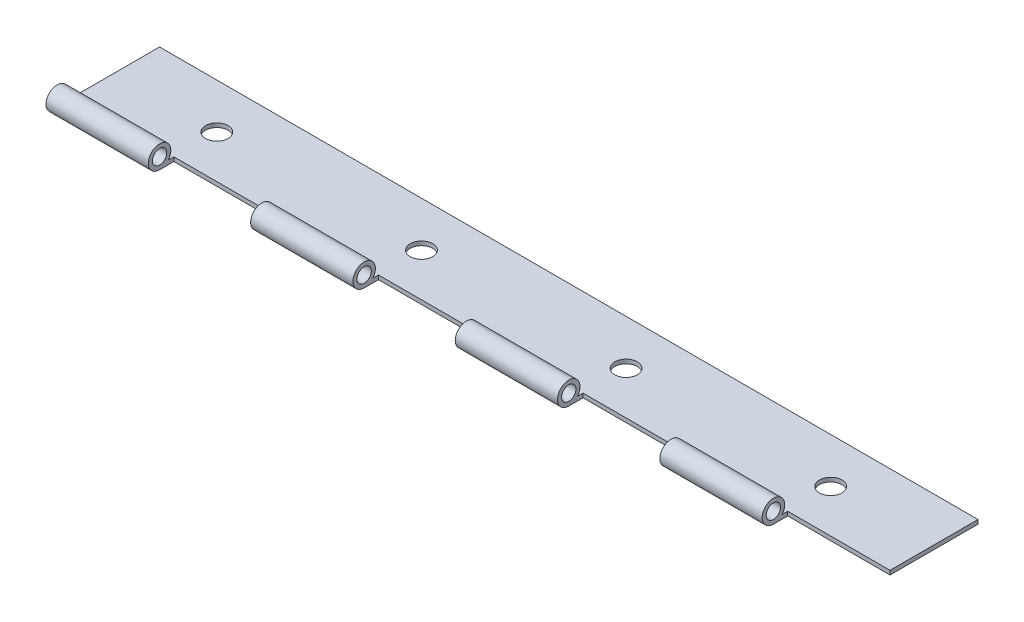
from build123d import *

# Parameters (mm, degrees)
SKETCH1_R           = 1.778
BOSS_EXTRUDE1_DEPTH = 101.6
SKETCH2_R           = 2.794
SKETCH2_W           = 25.4
SKETCH2_H           = 6.35
CUT_EXTRUDE1_DEPTH  = 914.4
LPATTERN1_COUNT     = 3
LPATTERN1_PITCH     = 50.8
LPATTERN2_COUNT     = 3
LPATTERN2_PITCH     = 50.8


with BuildPart() as part:
    # Sketch1 → Boss-Extrude1 (new body, symmetric)
    with BuildSketch(Plane(origin=(0, 0, 0), x_dir=(0, 0, -1), z_dir=(1, 0, 0))):
        with BuildLine():
            Line((0, -2.794), (25.4, -2.794))
            Line((25.4, -2.794), (25.4, -1.778))
            Line((25.4, -1.778), (2.155261469, -1.778))
            ThreePointArc((2.155261469, -1.778), (-1.191365603, 2.52726809), (0, -2.794))
        make_face()
        Circle(SKETCH1_R, mode=Mode.SUBTRACT)
    extrude(amount=BOSS_EXTRUDE1_DEPTH, both=True)

    # Sketch2 → Cut-Extrude1 (cut, symmetric)
    with BuildSketch(Plane(origin=(0, -1.778, 0), x_dir=(1, 0, 0), z_dir=(0, 1, 0))):
        with Locations((-25.4, 14.224)):
            Circle(SKETCH2_R)
        with Locations((-12.7, 0.381)):
            Rectangle(SKETCH2_W, SKETCH2_H)
    cut_extrude1 = extrude(amount=CUT_EXTRUDE1_DEPTH, both=True, mode=Mode.SUBTRACT)

    # LPattern1: Cut-Extrude1 ×3
    with Locations(*[(-i * LPATTERN1_PITCH, 0, 0) for i in range(1, LPATTERN1_COUNT)]):
        add(cut_extrude1, mode=Mode.SUBTRACT)

    # LPattern2: Cut-Extrude1 ×3
    with Locations(*[(i * LPATTERN2_PITCH, 0, 0) for i in range(1, LPATTERN2_COUNT)]):
        add(cut_extrude1, mode=Mode.SUBTRACT)


solid = part.part
